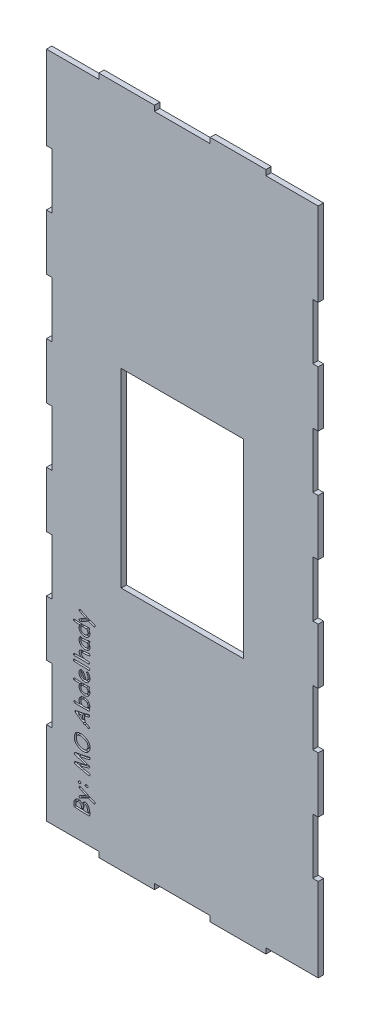
from build123d import *

# Parameters (mm, degrees)
BOSS_EXTRUDE1_DEPTH    = 50
BOSS_EXTRUDE1_2_DEPTH  = 50
BOSS_EXTRUDE1_3_DEPTH  = 50
BOSS_EXTRUDE1_4_DEPTH  = 50
SKETCH1_W              = 1143
SKETCH1_H              = 1778
BOSS_EXTRUDE1_5_DEPTH  = 50
BOSS_EXTRUDE1_6_DEPTH  = 50
BOSS_EXTRUDE1_7_DEPTH  = 50
BOSS_EXTRUDE1_8_DEPTH  = 50
BOSS_EXTRUDE1_9_DEPTH  = 50
BOSS_EXTRUDE1_10_DEPTH = 50
BOSS_EXTRUDE2_DEPTH    = 30
SCALE1_SCALE           = 0.04


with BuildPart() as part:
    # Sketch1 → Boss-Extrude1 (new body)
    with BuildSketch(Plane.XY):
        with BuildLine():
            ThreePointArc((364.602054386, 367.479719192), (356.103541918, 357.918130667), (351.763572316, 345.884288672))
            Line((351.763572316, 345.884288672), (349.060652398, 338.340317984))
            ThreePointArc((349.060652398, 338.340317984), (347.635408414, 324.356297827), (346.919418428, 310.318082182))
            ThreePointArc((346.919418428, 310.318082182), (367.025808597, 309.852333871), (387.137378124, 309.759499352))
            ThreePointArc((387.137378124, 309.759499352), (384.434694065, 333.914018803), (376.327369264, 356.82725942))
            ThreePointArc((376.327369264, 356.82725942), (371.535753699, 363.33240042), (364.602054386, 367.479719192))
        make_face()
    extrude(amount=BOSS_EXTRUDE1_DEPTH)



with BuildPart() as body_2:
    # Sketch1 → Boss-Extrude1 2 (new body)
    with BuildSketch(Plane.XY):
        with BuildLine():
            ThreePointArc((293.795869354, 894.76440173), (283.089924567, 880.6651647), (280.051036544, 863.224668772))
            Line((280.051036544, 863.224668772), (279.79638859, 858.287782786))
            ThreePointArc((279.79638859, 858.287782786), (288.522942613, 833.431164151), (308.39408095, 816.135439354))
            ThreePointArc((308.39408095, 816.135439354), (335.994182242, 805.80189598), (365.324004682, 808.684468734))
            ThreePointArc((365.324004682, 808.684468734), (388.054256437, 850.794430281), (360.561210296, 889.961324722))
            ThreePointArc((360.561210296, 889.961324722), (327.74688214, 900.263125567), (293.795869354, 894.76440173))
        make_face()
    extrude(amount=BOSS_EXTRUDE1_2_DEPTH)


with BuildPart() as body_3:
    # Sketch1 → Boss-Extrude1 3 (new body)
    with BuildSketch(Plane.XY):
        Polygon((334.072014608, 1075.483384462), (298.136522852, 1067.942517146), (341.054299348, 1041.316738292), align=None)
    extrude(amount=BOSS_EXTRUDE1_3_DEPTH)


with BuildPart() as body_4:
    # Sketch1 → Boss-Extrude1 4 (new body)
    with BuildSketch(Plane.XY):
        with BuildLine():
            ThreePointArc((321.224610788, 1402.905986918), (329.409666221, 1384.822326042), (346.998192972, 1375.621366862))
            Line((346.998192972, 1375.621366862), (356.508422618, 1372.742517146))
            ThreePointArc((356.508422618, 1372.742517146), (343.736107756, 1399.648767607), (328.672381262, 1425.342394928))
            ThreePointArc((328.672381262, 1425.342394928), (322.990411802, 1414.774177403), (321.224610788, 1402.905986918))
        make_face()
    extrude(amount=BOSS_EXTRUDE1_4_DEPTH)


with BuildPart() as body_5:
    # Sketch1 → Boss-Extrude1 5 (new body)
    with BuildSketch(Plane.XY):
        Polygon((488.95, 6299.2), (0, 6299.2), (0, 5518.15), (50.8, 5518.15), (50.8, 4997.45), (0, 4997.45), (0, 4476.75), (50.8, 4476.75), (50.8, 3956.05), (0, 3956.05), (0, 3435.35), (50.8, 3435.35), (50.8, 2914.65), (0, 2914.65), (0, 2393.95), (50.8, 2393.95), (50.8, 1873.25), (0, 1873.25), (0, 1352.55), (50.8, 1352.55), (50.8, 831.85), (0, 831.85), (0, 50.8), (488.95, 50.8), (488.95, 0), (1009.65, 0), (1009.65, 50.8), (1530.35, 50.8), (1530.35, 0), (2051.05, 0), (2051.05, 50.8), (2540, 50.8), (2540, 831.85), (2489.2, 831.85), (2489.2, 1352.55), (2540, 1352.55), (2540, 1873.25), (2489.2, 1873.25), (2489.2, 2393.95), (2540, 2393.95), (2540, 2914.65), (2489.2, 2914.65), (2489.2, 3435.35), (2540, 3435.35), (2540, 3956.05), (2489.2, 3956.05), (2489.2, 4476.75), (2540, 4476.75), (2540, 4997.45), (2489.2, 4997.45), (2489.2, 5518.15), (2540, 5518.15), (2540, 6299.2), (2051.05, 6299.2), (2051.05, 6350), (1530.35, 6350), (1530.35, 6299.2), (1009.65, 6299.2), (1009.65, 6350), (488.95, 6350), align=None)
        with BuildLine():
            ThreePointArc((296.833163, 518.616258168), (301.04254699, 527.3167164), (310.404009112, 529.720861562))
            Line((310.404009112, 529.720861562), (312.752772004, 529.934209116))
            ThreePointArc((312.752772004, 529.934209116), (322.160831041, 520.391753474), (312.752772004, 510.849297832))
            ThreePointArc((312.752772004, 510.849297832), (302.910933634, 510.875253047), (296.833163, 518.616258168))
        make_face(mode=Mode.SUBTRACT)
        with BuildLine():
            ThreePointArc((398.029742166, 356.02877232), (405.014628635, 327.732326972), (405.291318194, 298.587843768))
            ThreePointArc((405.291318194, 298.587843768), (396.666611095, 292.034543239), (385.85783382, 291.32626774))
            ThreePointArc((385.85783382, 291.32626774), (324.264844298, 292.744290856), (262.79286278, 296.855572404))
            ThreePointArc((262.79286278, 296.855572404), (258.639720091, 301.567357798), (257.541942878, 307.751563566))
            ThreePointArc((257.541942878, 307.751563566), (257.662270063, 340.716793903), (275.487155146, 368.447541488))
            ThreePointArc((275.487155146, 368.447541488), (307.315367517, 376.072902168), (335.284216908, 359.075117256))
            ThreePointArc((335.284216908, 359.075117256), (335.669623761, 358.33895043), (336.405790484, 358.72435748))
            ThreePointArc((336.405790484, 358.72435748), (345.116517247, 374.13793343), (359.2813871, 384.75921143))
            ThreePointArc((359.2813871, 384.75921143), (374.479955795, 383.614910379), (386.508972472, 374.254959896))
            ThreePointArc((386.508972472, 374.254959896), (392.906026119, 365.544304335), (398.029742166, 356.02877232))
        make_face(mode=Mode.SUBTRACT)
        with BuildLine():
            ThreePointArc((307.973786155, 473.848361169), (307.032158337, 485.749771307), (318.710988477, 488.226695363))
            ThreePointArc((318.710988477, 488.226695363), (380.882556482, 459.304064262), (444.29300905, 433.209295378))
            ThreePointArc((444.29300905, 433.209295378), (450.625721654, 430.763950244), (454.912087888, 425.499918874))
            ThreePointArc((454.912087888, 425.499918874), (451.270170402, 415.332204503), (440.483090838, 414.798450818))
            ThreePointArc((440.483090838, 414.798450818), (416.407170412, 423.672140626), (392.816303012, 433.764875166))
            ThreePointArc((392.816303012, 433.764875166), (354.556055846, 413.360834042), (315.786186816, 393.942578128))
            ThreePointArc((315.786186816, 393.942578128), (305.690485268, 402.245428226), (313.131232279, 412.992325147))
            ThreePointArc((313.131232279, 412.992325147), (341.489667794, 429.428186775), (370.938477599, 443.819365093))
            ThreePointArc((370.938477599, 443.819365093), (338.817842293, 457.495499817), (307.973786155, 473.848361169))
        make_face(mode=Mode.SUBTRACT)
        with BuildLine():
            ThreePointArc((364.444952797, 513.74694586), (363.089015354, 525.419049684), (373.452100186, 530.95827768))
            Line((373.452100186, 530.95827768), (380.713676214, 531.51686051))
            ThreePointArc((380.713676214, 531.51686051), (390.121734194, 521.97440473), (380.713676165, 512.431948998))
            ThreePointArc((380.713676165, 512.431948998), (372.438527222, 511.34767219), (364.444952797, 513.74694586))
        make_face(mode=Mode.SUBTRACT)
        with BuildLine():
            ThreePointArc((400.692320026, 679.918338662), (358.204091549, 666.637343998), (314.66757488, 657.352620268))
            Line((314.66757488, 657.352620268), (309.12198399, 656.173915996))
            ThreePointArc((309.12198399, 656.173915996), (354.753511067, 645.804400773), (400.543364776, 636.158033243))
            ThreePointArc((400.543364776, 636.158033243), (406.842569101, 624.27922809), (395.183630002, 617.581831128))
            ThreePointArc((395.183630002, 617.581831128), (364.296334178, 622.604908956), (334.072014608, 630.713352744))
            Line((334.072014608, 630.713352744), (275.080760226, 643.87604397))
            ThreePointArc((275.080760226, 643.87604397), (266.85028211, 647.552390968), (261.089037638, 654.485237382))
            ThreePointArc((261.089037638, 654.485237382), (263.482440946, 663.654840013), (272.024994938, 667.757858792))
            Line((272.024994938, 667.757858792), (347.99575181, 684.419911574))
            Line((347.99575181, 684.419911574), (367.307689564, 689.502688048))
            ThreePointArc((367.307689564, 689.502688048), (318.662047534, 705.420495656), (269.32296148, 719.037752168))
            ThreePointArc((269.32296148, 719.037752168), (261.048950822, 724.700035587), (260.322464114, 734.699681728))
            ThreePointArc((260.322464114, 734.699681728), (272.547597654, 742.098905096), (286.602823034, 744.678253084))
            ThreePointArc((286.602823034, 744.678253084), (340.00069894, 754.036141162), (392.773335102, 766.443884432))
            ThreePointArc((392.773335102, 766.443884432), (403.340388587, 766.816394214), (409.480689038, 758.20836928))
            ThreePointArc((409.480689038, 758.20836928), (404.752784952, 750.512685523), (396.521568652, 746.794661348))
            ThreePointArc((396.521568652, 746.794661348), (352.251300318, 737.225183726), (307.632429946, 729.441356456))
            ThreePointArc((307.632429946, 729.441356456), (353.696952868, 714.630084404), (399.123633552, 697.964829112))
            ThreePointArc((399.123633552, 697.964829112), (405.127119098, 689.395256471), (400.692320026, 679.918338662))
        make_face(mode=Mode.SUBTRACT)
        with BuildLine():
            ThreePointArc((407.432552164, 849.909041098), (397.118481173, 813.005048304), (367.119045542, 789.165614452))
            ThreePointArc((367.119045542, 789.165614452), (310.779591158, 793.066276398), (267.753159692, 829.645990438))
            ThreePointArc((267.753159692, 829.645990438), (260.713840394, 867.674486477), (274.489852086, 903.812278732))
            ThreePointArc((274.489852086, 903.812278732), (294.401826769, 915.550132715), (317.227505752, 919.190507818))
            ThreePointArc((317.227505752, 919.190507818), (363.899009872, 909.810396122), (400.031330492, 878.81569982))
            ThreePointArc((400.031330492, 878.81569982), (405.468396548, 864.806970097), (407.432552164, 849.909041098))
        make_face(mode=Mode.SUBTRACT)
        with BuildLine():
            ThreePointArc((400.853688517, 1012.366117246), (401.108323828, 999.738593356), (388.531249098, 998.582570014))
            Line((388.531249098, 998.582570014), (359.95301644, 1010.529517672))
            ThreePointArc((359.95301644, 1010.529517672), (350.628089876, 1010.614875598), (345.243670192, 1018.228650356))
            ThreePointArc((345.243670192, 1018.228650356), (305.276069911, 1041.513295189), (267.306411284, 1067.930879882))
            ThreePointArc((267.306411284, 1067.930879882), (264.770421314, 1074.879482878), (269.459282264, 1080.60040166))
            ThreePointArc((269.459282264, 1080.60040166), (296.048691133, 1087.042205001), (322.931391474, 1092.122944782))
            ThreePointArc((322.931391474, 1092.122944782), (351.876214883, 1098.09874472), (380.38225041, 1105.903802412))
            ThreePointArc((380.38225041, 1105.903802412), (389.347948352, 1109.014477886), (398.821067736, 1109.580208064))
            ThreePointArc((398.821067736, 1109.580208064), (402.782653414, 1105.910026555), (404.546541172, 1100.805803464))
            ThreePointArc((404.546541172, 1100.805803464), (399.307868421, 1093.120169441), (391.0570411, 1088.82639359))
            ThreePointArc((391.0570411, 1088.82639359), (372.309327299, 1083.685834533), (353.250023242, 1079.858949498))
            ThreePointArc((353.250023242, 1079.858949498), (357.570547363, 1054.742833849), (363.600321825, 1029.981411962))
            ThreePointArc((363.600321825, 1029.981411962), (382.578519169, 1021.917157213), (400.853688517, 1012.366117246))
        make_face(mode=Mode.SUBTRACT)
        with BuildLine():
            ThreePointArc((257.15051186, 1154.359926988), (266.118841383, 1155.891648274), (275.18384892, 1155.11528311))
            Line((275.18384892, 1155.11528311), (314.987103324, 1154.709041098))
            ThreePointArc((314.987103324, 1154.709041098), (304.650342929, 1180.565261338), (311.362133688, 1207.590149966))
            ThreePointArc((311.362133688, 1207.590149966), (349.921694176, 1228.307837632), (391.266017568, 1213.930452246))
            ThreePointArc((391.266017568, 1213.930452246), (401.758211762, 1198.530984035), (405.663706832, 1180.310751642))
            ThreePointArc((405.663706832, 1180.310751642), (403.894732846, 1167.149256498), (400.07787904, 1154.42974981))
            ThreePointArc((400.07787904, 1154.42974981), (403.189893635, 1143.530661817), (392.901641932, 1138.773915996))
            ThreePointArc((392.901641932, 1138.773915996), (328.927994708, 1138.092684118), (264.959033454, 1139.123999878))
            ThreePointArc((264.959033454, 1139.123999878), (256.742078026, 1144.531676595), (257.15051186, 1154.359926988))
        make_face(mode=Mode.SUBTRACT)
        with BuildLine():
            ThreePointArc((258.017478879, 1323.453405923), (254.736621523, 1335.117443268), (266.156124532, 1339.168213962))
            Line((266.156124532, 1339.168213962), (319.548862552, 1335.68985973))
            ThreePointArc((319.548862552, 1335.68985973), (358.592836344, 1335.324217194), (397.587530706, 1337.319059418))
            ThreePointArc((397.587530706, 1337.319059418), (403.970578604, 1328.649607544), (396.598373951, 1320.804016755))
            ThreePointArc((396.598373951, 1320.804016755), (398.597590637, 1315.613452139), (401.603239713, 1310.933184837))
            ThreePointArc((401.603239713, 1310.933184837), (396.682153097, 1264.425164874), (353.270847427, 1247.027706603))
            ThreePointArc((353.270847427, 1247.027706603), (320.908443546, 1258.957543649), (305.063167363, 1289.593689289))
            ThreePointArc((305.063167363, 1289.593689289), (306.465555063, 1305.526539646), (314.428520489, 1319.397862345))
            ThreePointArc((314.428520489, 1319.397862345), (286.151104792, 1320.425604009), (258.017478879, 1323.453405923))
        make_face(mode=Mode.SUBTRACT)
        with BuildLine():
            ThreePointArc((406.036095216, 1405.419609272), (400.618323077, 1380.025845103), (382.632142024, 1361.299051336))
            ThreePointArc((382.632142024, 1361.299051336), (345.83682468, 1358.368204346), (313.823389116, 1376.742784228))
            ThreePointArc((313.823389116, 1376.742784228), (304.296643932, 1404.984185302), (313.322992098, 1433.389477894))
            ThreePointArc((313.322992098, 1433.389477894), (333.560195461, 1438.935622101), (348.967555302, 1424.690715002))
            ThreePointArc((348.967555302, 1424.690715002), (361.638739389, 1399.672434907), (373.638294378, 1374.325168286))
            ThreePointArc((373.638294378, 1374.325168286), (387.500859734, 1394.384702981), (387.154002678, 1418.76574768))
            ThreePointArc((387.154002678, 1418.76574768), (382.456832319, 1429.57637291), (374.778734312, 1438.519517672))
            ThreePointArc((374.778734312, 1438.519517672), (378.966240567, 1448.970756408), (389.99429621, 1446.702367448))
            ThreePointArc((389.99429621, 1446.702367448), (402.014799366, 1427.615168379), (406.036095216, 1405.419609272))
        make_face(mode=Mode.SUBTRACT)
        with BuildLine():
            ThreePointArc((257.197060402, 1473.205956303), (253.174955865, 1485.98992613), (265.638728818, 1490.915529974))
            Line((265.638728818, 1490.915529974), (328.579283912, 1490.044899508))
            ThreePointArc((328.579283912, 1490.044899508), (364.583778523, 1489.315955792), (400.5200905, 1486.984331334))
            ThreePointArc((400.5200905, 1486.984331334), (404.53874298, 1474.64092392), (392.505979257, 1469.770413522))
            ThreePointArc((392.505979257, 1469.770413522), (324.846617774, 1471.295117352), (257.197060402, 1473.205956303))
        make_face(mode=Mode.SUBTRACT)
        with BuildLine():
            ThreePointArc((265.190881352, 1539.13573173), (293.422410526, 1539.833160152), (321.654289888, 1539.150054282))
            Line((321.654289888, 1539.150054282), (326.065661558, 1539.200183468))
            ThreePointArc((326.065661558, 1539.200183468), (309.29364747, 1559.21718308), (307.62544774, 1585.27860744))
            ThreePointArc((307.62544774, 1585.27860744), (317.710759023, 1595.994472542), (332.084593386, 1599.14663914))
            ThreePointArc((332.084593386, 1599.14663914), (365.692461311, 1601.91245371), (399.174060934, 1605.927550648))
            ThreePointArc((399.174060934, 1605.927550648), (405.128397796, 1602.821406623), (407.525649275, 1596.548014915))
            ThreePointArc((407.525649275, 1596.548014915), (403.070502045, 1589.265800067), (394.872419565, 1586.884532845))
            ThreePointArc((394.872419565, 1586.884532845), (364.660194586, 1583.168118296), (334.234934541, 1582.222694315))
            ThreePointArc((334.234934541, 1582.222694315), (326.781089023, 1578.607548769), (324.791394627, 1570.565769953))
            ThreePointArc((324.791394627, 1570.565769953), (333.669669632, 1554.276845664), (349.020892269, 1543.860858669))
            ThreePointArc((349.020892269, 1543.860858669), (356.552631048, 1540.358217189), (364.826133963, 1539.620154933))
            ThreePointArc((364.826133963, 1539.620154933), (382.05302796, 1539.28842486), (398.991745845, 1536.133150223))
            ThreePointArc((398.991745845, 1536.133150223), (401.903896619, 1523.611425474), (389.532513313, 1520.11527217))
            ThreePointArc((389.532513313, 1520.11527217), (331.216024616, 1522.027294077), (272.869962031, 1521.573793764))
            ThreePointArc((272.869962031, 1521.573793764), (264.158355297, 1520.535669844), (255.695869379, 1522.850000254))
            ThreePointArc((255.695869379, 1522.850000254), (254.365594485, 1534.536372914), (265.190881352, 1539.13573173))
        make_face(mode=Mode.SUBTRACT)
        with BuildLine():
            ThreePointArc((407.898037898, 1701.4684792), (403.027879825, 1694.642324378), (397.005673856, 1688.807269572))
            ThreePointArc((397.005673856, 1688.807269572), (404.004231443, 1673.241777383), (406.374256846, 1656.340672834))
            ThreePointArc((406.374256846, 1656.340672834), (396.50097768, 1632.637741616), (373.267360652, 1621.705695622))
            ThreePointArc((373.267360652, 1621.705695622), (329.255472635, 1629.358187023), (305.148927166, 1666.96777858))
            ThreePointArc((305.148927166, 1666.96777858), (306.705082818, 1686.694838268), (317.774198588, 1703.097678888))
            ThreePointArc((317.774198588, 1703.097678888), (323.411984328, 1703.127323031), (328.848775626, 1701.63507399))
            ThreePointArc((328.848775626, 1701.63507399), (355.066372923, 1699.642276056), (381.112663986, 1703.237324532))
            ThreePointArc((381.112663986, 1703.237324532), (390.627454781, 1707.042542904), (400.465783776, 1709.909285534))
            ThreePointArc((400.465783776, 1709.909285534), (405.722220619, 1707.045147784), (407.898037898, 1701.4684792))
        make_face(mode=Mode.SUBTRACT)
        with BuildLine():
            ThreePointArc((258.017478879, 1799.831414557), (254.736621523, 1811.495451902), (266.156124532, 1815.546222596))
            Line((266.156124532, 1815.546222596), (319.548862552, 1812.067868364))
            ThreePointArc((319.548862552, 1812.067868364), (358.592836344, 1811.702225828), (397.587530706, 1813.697068052))
            ThreePointArc((397.587530706, 1813.697068052), (403.970578511, 1805.027616203), (396.598373999, 1797.182025386))
            ThreePointArc((396.598373999, 1797.182025386), (398.597590662, 1791.991460775), (401.603239713, 1787.311193471))
            ThreePointArc((401.603239713, 1787.311193471), (396.682153097, 1740.803173508), (353.270847427, 1723.405715237))
            ThreePointArc((353.270847427, 1723.405715237), (320.908443595, 1735.335552156), (305.063167363, 1765.971697669))
            ThreePointArc((305.063167363, 1765.971697669), (306.465555063, 1781.904548026), (314.428520489, 1795.775870725))
            ThreePointArc((314.428520489, 1795.775870725), (286.151104787, 1796.803612516), (258.017478879, 1799.831414557))
        make_face(mode=Mode.SUBTRACT)
        with BuildLine():
            ThreePointArc((307.973786155, 1905.496009171), (307.032158284, 1917.397419381), (318.710988461, 1919.87434363))
            ThreePointArc((318.710988461, 1919.87434363), (380.882556473, 1890.951712523), (444.29300905, 1864.856943634))
            ThreePointArc((444.29300905, 1864.856943634), (450.625721688, 1862.411598373), (454.912087888, 1857.147566876))
            ThreePointArc((454.912087888, 1857.147566876), (451.270170317, 1846.979852632), (440.483090838, 1846.446099074))
            ThreePointArc((440.483090838, 1846.446099074), (416.407170415, 1855.319788755), (392.816303012, 1865.412523168))
            ThreePointArc((392.816303012, 1865.412523168), (354.556055844, 1845.008482171), (315.786186816, 1825.590226384))
            ThreePointArc((315.786186816, 1825.590226384), (305.690485268, 1833.893076482), (313.131232279, 1844.639973403))
            ThreePointArc((313.131232279, 1844.639973403), (341.489667798, 1861.075834904), (370.938477599, 1875.467013095))
            ThreePointArc((370.938477599, 1875.467013095), (338.817842293, 1889.143147819), (307.973786155, 1905.496009171))
        make_face(mode=Mode.SUBTRACT)
        with Locations((1270, 3175)):
            Rectangle(SKETCH1_W, SKETCH1_H, mode=Mode.SUBTRACT)
    extrude(amount=BOSS_EXTRUDE1_5_DEPTH)


with BuildPart() as body_6:
    # Sketch1 → Boss-Extrude1 6 (new body)
    with BuildSketch(Plane.XY):
        with BuildLine():
            ThreePointArc((279.649392948, 344.347532792), (275.924642305, 336.489956633), (274.489852086, 327.913439422))
            ThreePointArc((274.489852086, 327.913439422), (274.303894833, 320.713917745), (275.768147218, 313.662417378))
            ThreePointArc((275.768147218, 313.662417378), (301.627756611, 312.961664931), (327.462118506, 311.621442034))
            ThreePointArc((327.462118506, 311.621442034), (326.781637673, 334.446662277), (314.28887485, 353.561698514))
            ThreePointArc((314.28887485, 353.561698514), (294.751415788, 357.291844295), (279.649392948, 344.347532792))
        make_face()
    extrude(amount=BOSS_EXTRUDE1_6_DEPTH)


with BuildPart() as body_7:
    # Sketch1 → Boss-Extrude1 7 (new body)
    with BuildSketch(Plane.XY):
        with BuildLine():
            ThreePointArc((340.999604766, 1208.943937454), (327.222503119, 1199.547397796), (321.596999426, 1183.84844256))
            ThreePointArc((321.596999426, 1183.84844256), (325.971574491, 1168.017082241), (335.715537102, 1154.794976918))
            ThreePointArc((335.715537102, 1154.794976918), (358.484865763, 1154.130052825), (381.229942136, 1155.373416198))
            ThreePointArc((381.229942136, 1155.373416198), (387.63549882, 1175.82042103), (383.227298568, 1196.788943476))
            ThreePointArc((383.227298568, 1196.788943476), (364.127854332, 1209.864681605), (340.999604766, 1208.943937454))
        make_face()
    extrude(amount=BOSS_EXTRUDE1_7_DEPTH)


with BuildPart() as body_8:
    # Sketch1 → Boss-Extrude1 8 (new body)
    with BuildSketch(Plane.XY):
        with BuildLine():
            ThreePointArc((336.0377963, 1317.181434466), (325.830674158, 1307.723597407), (321.96938781, 1294.354734628))
            ThreePointArc((321.96938781, 1294.354734628), (329.212691399, 1273.78534243), (348.65156203, 1263.9012314))
            ThreePointArc((348.65156203, 1263.9012314), (375.42586568, 1268.318739422), (388.38061262, 1292.163073022))
            ThreePointArc((388.38061262, 1292.163073022), (384.470019327, 1306.693613406), (374.3222003, 1317.804469034))
            ThreePointArc((374.3222003, 1317.804469034), (355.171668452, 1318.004806575), (336.0377963, 1317.181434466))
        make_face()
    extrude(amount=BOSS_EXTRUDE1_8_DEPTH)


with BuildPart() as body_9:
    # Sketch1 → Boss-Extrude1 9 (new body)
    with BuildSketch(Plane.XY):
        with BuildLine():
            ThreePointArc((378.305785424, 1684.891870494), (360.776976392, 1683.166605795), (343.195533318, 1682.104276374))
            ThreePointArc((343.195533318, 1682.104276374), (333.75338958, 1683.267644094), (324.246035784, 1683.610757232))
            ThreePointArc((324.246035784, 1683.610757232), (322.144014321, 1666.211331272), (331.137515524, 1651.168876218))
            ThreePointArc((331.137515524, 1651.168876218), (355.844857786, 1639.06039085), (382.854910184, 1644.306841936))
            ThreePointArc((382.854910184, 1644.306841936), (390.711204253, 1662.333024575), (383.50659011, 1680.629421818))
            ThreePointArc((383.50659011, 1680.629421818), (381.563061989, 1683.562127838), (378.305785424, 1684.891870494))
        make_face()
    extrude(amount=BOSS_EXTRUDE1_9_DEPTH)


with BuildPart() as body_10:
    # Sketch1 → Boss-Extrude1 10 (new body)
    with BuildSketch(Plane.XY):
        with BuildLine():
            ThreePointArc((336.0377963, 1793.559442846), (325.830674158, 1784.101605787), (321.96938781, 1770.732743008))
            ThreePointArc((321.96938781, 1770.732743008), (329.212691449, 1750.163350937), (348.65156203, 1740.279240034))
            ThreePointArc((348.65156203, 1740.279240034), (375.425865618, 1744.696747929), (388.38061262, 1768.541081402))
            ThreePointArc((388.38061262, 1768.541081402), (384.470019357, 1783.071621913), (374.3222003, 1794.182477668))
            ThreePointArc((374.3222003, 1794.182477668), (355.171668449, 1794.382815082), (336.0377963, 1793.559442846))
        make_face()
    extrude(amount=BOSS_EXTRUDE1_10_DEPTH)


with BuildPart() as part_1:
    add(part.part)

    add(body_2.part)  # Boss-Extrude2 merges body 2

    add(body_3.part)  # Boss-Extrude2 merges body 3

    add(body_4.part)  # Boss-Extrude2 merges body 4

    add(body_5.part)  # Boss-Extrude2 merges body 5

    add(body_6.part)  # Boss-Extrude2 merges body 6

    add(body_7.part)  # Boss-Extrude2 merges body 7

    add(body_8.part)  # Boss-Extrude2 merges body 8

    add(body_9.part)  # Boss-Extrude2 merges body 9

    add(body_10.part)  # Boss-Extrude2 merges body 10
    # Sketch1_3 → Boss-Extrude2 (add)
    # profile 1 of 15: a face of its own
    with BuildSketch(Plane.XY):
        with BuildLine():
            Line((380.713676214, 531.51686051), (373.452100186, 530.95827768))
            ThreePointArc((373.452100186, 530.95827768), (363.089015354, 525.419049684), (364.444952797, 513.74694586))
            ThreePointArc((364.444952797, 513.74694586), (372.438527222, 511.34767219), (380.713676165, 512.431948998))
            ThreePointArc((380.713676165, 512.431948998), (390.121734194, 521.97440473), (380.713676214, 531.51686051))
        make_face()
    # profile 2 of 15: a face of its own
    with BuildSketch(Plane.XY):
        with BuildLine():
            Line((312.752772004, 529.934209116), (310.404009112, 529.720861562))
            ThreePointArc((310.404009112, 529.720861562), (301.04254699, 527.3167164), (296.833163, 518.616258168))
            ThreePointArc((296.833163, 518.616258168), (302.910933634, 510.875253047), (312.752772004, 510.849297832))
            ThreePointArc((312.752772004, 510.849297832), (322.160831041, 520.391753474), (312.752772004, 529.934209116))
        make_face()
    # profile 3 of 15: a face of its own
    with BuildSketch(Plane.XY):
        with BuildLine():
            Line((309.12198399, 656.173915996), (314.66757488, 657.352620268))
            ThreePointArc((314.66757488, 657.352620268), (358.204091549, 666.637343998), (400.692320026, 679.918338662))
            ThreePointArc((400.692320026, 679.918338662), (405.127119098, 689.395256471), (399.123633552, 697.964829112))
            ThreePointArc((399.123633552, 697.964829112), (353.696952868, 714.630084404), (307.632429946, 729.441356456))
            ThreePointArc((307.632429946, 729.441356456), (352.251300318, 737.225183726), (396.521568652, 746.794661348))
            ThreePointArc((396.521568652, 746.794661348), (404.752784952, 750.512685523), (409.480689038, 758.20836928))
            ThreePointArc((409.480689038, 758.20836928), (403.340388587, 766.816394214), (392.773335102, 766.443884432))
            ThreePointArc((392.773335102, 766.443884432), (340.00069894, 754.036141162), (286.602823034, 744.678253084))
            ThreePointArc((286.602823034, 744.678253084), (272.547597654, 742.098905096), (260.322464114, 734.699681728))
            ThreePointArc((260.322464114, 734.699681728), (261.048950822, 724.700035587), (269.32296148, 719.037752168))
            ThreePointArc((269.32296148, 719.037752168), (318.662047534, 705.420495656), (367.307689564, 689.502688048))
            Line((367.307689564, 689.502688048), (347.99575181, 684.419911574))
            Line((347.99575181, 684.419911574), (272.024994938, 667.757858792))
            ThreePointArc((272.024994938, 667.757858792), (263.482440946, 663.654840013), (261.089037638, 654.485237382))
            ThreePointArc((261.089037638, 654.485237382), (266.85028211, 647.552390968), (275.080760226, 643.87604397))
            Line((275.080760226, 643.87604397), (334.072014608, 630.713352744))
            ThreePointArc((334.072014608, 630.713352744), (364.296334178, 622.604908956), (395.183630002, 617.581831128))
            ThreePointArc((395.183630002, 617.581831128), (406.842569101, 624.27922809), (400.543364776, 636.158033243))
            ThreePointArc((400.543364776, 636.158033243), (354.753511067, 645.804400773), (309.12198399, 656.173915996))
        make_face()
    # profile 4 of 15: a face of its own
    with BuildSketch(Plane.XY):
        with BuildLine():
            Line((359.95301644, 1010.529517672), (388.531249098, 998.582570014))
            ThreePointArc((388.531249098, 998.582570014), (401.108323828, 999.738593356), (400.853688517, 1012.366117246))
            ThreePointArc((400.853688517, 1012.366117246), (382.578519169, 1021.917157213), (363.600321825, 1029.981411962))
            ThreePointArc((363.600321825, 1029.981411962), (357.570547363, 1054.742833849), (353.250023242, 1079.858949498))
            ThreePointArc((353.250023242, 1079.858949498), (372.309327299, 1083.685834533), (391.0570411, 1088.82639359))
            ThreePointArc((391.0570411, 1088.82639359), (399.307868421, 1093.120169441), (404.546541172, 1100.805803464))
            ThreePointArc((404.546541172, 1100.805803464), (402.782653414, 1105.910026555), (398.821067736, 1109.580208064))
            ThreePointArc((398.821067736, 1109.580208064), (389.347948352, 1109.014477886), (380.38225041, 1105.903802412))
            ThreePointArc((380.38225041, 1105.903802412), (351.876214883, 1098.09874472), (322.931391474, 1092.122944782))
            ThreePointArc((322.931391474, 1092.122944782), (296.048691133, 1087.042205001), (269.459282264, 1080.60040166))
            ThreePointArc((269.459282264, 1080.60040166), (264.770421314, 1074.879482878), (267.306411284, 1067.930879882))
            ThreePointArc((267.306411284, 1067.930879882), (305.276069911, 1041.513295189), (345.243670192, 1018.228650356))
            ThreePointArc((345.243670192, 1018.228650356), (350.628089876, 1010.614875598), (359.95301644, 1010.529517672))
        make_face()
        Polygon((341.054299348, 1041.316738292), (298.136522852, 1067.942517146), (334.072014608, 1075.483384462), align=None, mode=Mode.SUBTRACT)
    # profile 5 of 15: a face of its own
    with BuildSketch(Plane.XY):
        with BuildLine():
            Line((314.987103324, 1154.709041098), (275.18384892, 1155.11528311))
            ThreePointArc((275.18384892, 1155.11528311), (266.118841383, 1155.891648274), (257.15051186, 1154.359926988))
            ThreePointArc((257.15051186, 1154.359926988), (256.742078026, 1144.531676595), (264.959033454, 1139.123999878))
            ThreePointArc((264.959033454, 1139.123999878), (328.927994708, 1138.092684118), (392.901641932, 1138.773915996))
            ThreePointArc((392.901641932, 1138.773915996), (403.189893635, 1143.530661817), (400.07787904, 1154.42974981))
            ThreePointArc((400.07787904, 1154.42974981), (403.894732846, 1167.149256498), (405.663706832, 1180.310751642))
            ThreePointArc((405.663706832, 1180.310751642), (401.758211762, 1198.530984035), (391.266017568, 1213.930452246))
            ThreePointArc((391.266017568, 1213.930452246), (349.921694176, 1228.307837632), (311.362133688, 1207.590149966))
            ThreePointArc((311.362133688, 1207.590149966), (304.650342929, 1180.565261338), (314.987103324, 1154.709041098))
        make_face()
        with BuildLine():
            ThreePointArc((335.715537102, 1154.794976918), (325.971574491, 1168.017082241), (321.596999426, 1183.84844256))
            ThreePointArc((321.596999426, 1183.84844256), (327.222503119, 1199.547397796), (340.999604766, 1208.943937454))
            ThreePointArc((340.999604766, 1208.943937454), (364.127854332, 1209.864681605), (383.227298568, 1196.788943476))
            ThreePointArc((383.227298568, 1196.788943476), (387.63549882, 1175.82042103), (381.229942136, 1155.373416198))
            ThreePointArc((381.229942136, 1155.373416198), (358.484865763, 1154.130052825), (335.715537102, 1154.794976918))
        make_face(mode=Mode.SUBTRACT)
    # profile 6 of 15: a face of its own
    with BuildSketch(Plane.XY):
        with BuildLine():
            Line((319.548862552, 1335.68985973), (266.156124532, 1339.168213962))
            ThreePointArc((266.156124532, 1339.168213962), (254.736621523, 1335.117443268), (258.017478879, 1323.453405923))
            ThreePointArc((258.017478879, 1323.453405923), (286.151104792, 1320.425604009), (314.428520489, 1319.397862345))
            ThreePointArc((314.428520489, 1319.397862345), (306.465555063, 1305.526539646), (305.063167363, 1289.593689289))
            ThreePointArc((305.063167363, 1289.593689289), (320.908443546, 1258.957543649), (353.270847427, 1247.027706603))
            ThreePointArc((353.270847427, 1247.027706603), (396.682153097, 1264.425164874), (401.603239713, 1310.933184837))
            ThreePointArc((401.603239713, 1310.933184837), (398.597590637, 1315.613452139), (396.598373951, 1320.804016755))
            ThreePointArc((396.598373951, 1320.804016755), (403.970578604, 1328.649607544), (397.587530706, 1337.319059418))
            ThreePointArc((397.587530706, 1337.319059418), (358.592836344, 1335.324217194), (319.548862552, 1335.68985973))
        make_face()
        with BuildLine():
            ThreePointArc((348.65156203, 1263.9012314), (329.212691399, 1273.78534243), (321.96938781, 1294.354734628))
            ThreePointArc((321.96938781, 1294.354734628), (325.830674158, 1307.723597407), (336.0377963, 1317.181434466))
            ThreePointArc((336.0377963, 1317.181434466), (355.171668452, 1318.004806575), (374.3222003, 1317.804469034))
            ThreePointArc((374.3222003, 1317.804469034), (384.470019327, 1306.693613406), (388.38061262, 1292.163073022))
            ThreePointArc((388.38061262, 1292.163073022), (375.42586568, 1268.318739422), (348.65156203, 1263.9012314))
        make_face(mode=Mode.SUBTRACT)
    # profile 7 of 15: a face of its own
    with BuildSketch(Plane.XY):
        with BuildLine():
            Line((328.579283912, 1490.044899508), (265.638728818, 1490.915529974))
            ThreePointArc((265.638728818, 1490.915529974), (253.174955865, 1485.98992613), (257.197060402, 1473.205956303))
            ThreePointArc((257.197060402, 1473.205956303), (324.846617774, 1471.295117352), (392.505979257, 1469.770413522))
            ThreePointArc((392.505979257, 1469.770413522), (404.53874298, 1474.64092392), (400.5200905, 1486.984331334))
            ThreePointArc((400.5200905, 1486.984331334), (364.583778523, 1489.315955792), (328.579283912, 1490.044899508))
        make_face()
    # profile 8 of 15: a face of its own
    with BuildSketch(Plane.XY):
        with BuildLine():
            Line((326.065661558, 1539.200183468), (321.654289888, 1539.150054282))
            ThreePointArc((321.654289888, 1539.150054282), (293.422410526, 1539.833160152), (265.190881352, 1539.13573173))
            ThreePointArc((265.190881352, 1539.13573173), (254.365594485, 1534.536372914), (255.695869379, 1522.850000254))
            ThreePointArc((255.695869379, 1522.850000254), (264.158355297, 1520.535669844), (272.869962031, 1521.573793764))
            ThreePointArc((272.869962031, 1521.573793764), (331.216024616, 1522.027294077), (389.532513313, 1520.11527217))
            ThreePointArc((389.532513313, 1520.11527217), (401.903896619, 1523.611425474), (398.991745845, 1536.133150223))
            ThreePointArc((398.991745845, 1536.133150223), (382.05302796, 1539.28842486), (364.826133963, 1539.620154933))
            ThreePointArc((364.826133963, 1539.620154933), (356.552631048, 1540.358217189), (349.020892269, 1543.860858669))
            ThreePointArc((349.020892269, 1543.860858669), (333.669669632, 1554.276845664), (324.791394627, 1570.565769953))
            ThreePointArc((324.791394627, 1570.565769953), (326.781089023, 1578.607548769), (334.234934541, 1582.222694315))
            ThreePointArc((334.234934541, 1582.222694315), (364.660194586, 1583.168118296), (394.872419565, 1586.884532845))
            ThreePointArc((394.872419565, 1586.884532845), (403.070502045, 1589.265800067), (407.525649275, 1596.548014915))
            ThreePointArc((407.525649275, 1596.548014915), (405.128397796, 1602.821406623), (399.174060934, 1605.927550648))
            ThreePointArc((399.174060934, 1605.927550648), (365.692461311, 1601.91245371), (332.084593386, 1599.14663914))
            ThreePointArc((332.084593386, 1599.14663914), (317.710759023, 1595.994472542), (307.62544774, 1585.27860744))
            ThreePointArc((307.62544774, 1585.27860744), (309.29364747, 1559.21718308), (326.065661558, 1539.200183468))
        make_face()
    # profile 9 of 15: a face of its own
    with BuildSketch(Plane.XY):
        with BuildLine():
            Line((319.548862552, 1812.067868364), (266.156124532, 1815.546222596))
            ThreePointArc((266.156124532, 1815.546222596), (254.736621523, 1811.495451902), (258.017478879, 1799.831414557))
            ThreePointArc((258.017478879, 1799.831414557), (286.151104787, 1796.803612516), (314.428520489, 1795.775870725))
            ThreePointArc((314.428520489, 1795.775870725), (306.465555063, 1781.904548026), (305.063167363, 1765.971697669))
            ThreePointArc((305.063167363, 1765.971697669), (320.908443595, 1735.335552156), (353.270847427, 1723.405715237))
            ThreePointArc((353.270847427, 1723.405715237), (396.682153097, 1740.803173508), (401.603239713, 1787.311193471))
            ThreePointArc((401.603239713, 1787.311193471), (398.597590662, 1791.991460775), (396.598373999, 1797.182025386))
            ThreePointArc((396.598373999, 1797.182025386), (403.970578511, 1805.027616203), (397.587530706, 1813.697068052))
            ThreePointArc((397.587530706, 1813.697068052), (358.592836344, 1811.702225828), (319.548862552, 1812.067868364))
        make_face()
        with BuildLine():
            ThreePointArc((348.65156203, 1740.279240034), (329.212691449, 1750.163350937), (321.96938781, 1770.732743008))
            ThreePointArc((321.96938781, 1770.732743008), (325.830674158, 1784.101605787), (336.0377963, 1793.559442846))
            ThreePointArc((336.0377963, 1793.559442846), (355.171668449, 1794.382815082), (374.3222003, 1794.182477668))
            ThreePointArc((374.3222003, 1794.182477668), (384.470019357, 1783.071621913), (388.38061262, 1768.541081402))
            ThreePointArc((388.38061262, 1768.541081402), (375.425865618, 1744.696747929), (348.65156203, 1740.279240034))
        make_face(mode=Mode.SUBTRACT)
    # profile 10 of 15: a face of its own
    with BuildSketch(Plane.XY):
        with BuildLine():
            ThreePointArc((385.85783382, 291.32626774), (396.666611095, 292.034543239), (405.291318194, 298.587843768))
            ThreePointArc((405.291318194, 298.587843768), (405.014628635, 327.732326972), (398.029742166, 356.02877232))
            ThreePointArc((398.029742166, 356.02877232), (392.906026119, 365.544304335), (386.508972472, 374.254959896))
            ThreePointArc((386.508972472, 374.254959896), (374.479955795, 383.614910379), (359.2813871, 384.75921143))
            ThreePointArc((359.2813871, 384.75921143), (345.116517247, 374.13793343), (336.405790484, 358.72435748))
            ThreePointArc((336.405790484, 358.72435748), (335.669623761, 358.33895043), (335.284216908, 359.075117256))
            ThreePointArc((335.284216908, 359.075117256), (307.315367517, 376.072902168), (275.487155146, 368.447541488))
            ThreePointArc((275.487155146, 368.447541488), (257.662270063, 340.716793903), (257.541942878, 307.751563566))
            ThreePointArc((257.541942878, 307.751563566), (258.639720091, 301.567357798), (262.79286278, 296.855572404))
            ThreePointArc((262.79286278, 296.855572404), (324.264844298, 292.744290856), (385.85783382, 291.32626774))
        make_face()
        with BuildLine():
            ThreePointArc((275.768147218, 313.662417378), (274.303894833, 320.713917745), (274.489852086, 327.913439422))
            ThreePointArc((274.489852086, 327.913439422), (275.924642305, 336.489956633), (279.649392948, 344.347532792))
            ThreePointArc((279.649392948, 344.347532792), (294.751415788, 357.291844295), (314.28887485, 353.561698514))
            ThreePointArc((314.28887485, 353.561698514), (326.781637673, 334.446662277), (327.462118506, 311.621442034))
            ThreePointArc((327.462118506, 311.621442034), (301.627756611, 312.961664931), (275.768147218, 313.662417378))
        make_face(mode=Mode.SUBTRACT)
        with BuildLine():
            Line((349.060652398, 338.340317984), (351.763572316, 345.884288672))
            ThreePointArc((351.763572316, 345.884288672), (356.103541918, 357.918130667), (364.602054386, 367.479719192))
            ThreePointArc((364.602054386, 367.479719192), (371.535753699, 363.33240042), (376.327369264, 356.82725942))
            ThreePointArc((376.327369264, 356.82725942), (384.434694065, 333.914018803), (387.137378124, 309.759499352))
            ThreePointArc((387.137378124, 309.759499352), (367.025808597, 309.852333871), (346.919418428, 310.318082182))
            ThreePointArc((346.919418428, 310.318082182), (347.635408414, 324.356297827), (349.060652398, 338.340317984))
        make_face(mode=Mode.SUBTRACT)
    # profile 11 of 15: a face of its own
    with BuildSketch(Plane.XY):
        with BuildLine():
            ThreePointArc((444.29300905, 433.209295378), (380.882556482, 459.304064262), (318.710988477, 488.226695363))
            ThreePointArc((318.710988477, 488.226695363), (307.032158337, 485.749771307), (307.973786155, 473.848361169))
            ThreePointArc((307.973786155, 473.848361169), (338.817842293, 457.495499817), (370.938477599, 443.819365093))
            ThreePointArc((370.938477599, 443.819365093), (341.489667794, 429.428186775), (313.131232279, 412.992325147))
            ThreePointArc((313.131232279, 412.992325147), (305.690485268, 402.245428226), (315.786186816, 393.942578128))
            ThreePointArc((315.786186816, 393.942578128), (354.556055846, 413.360834042), (392.816303012, 433.764875166))
            ThreePointArc((392.816303012, 433.764875166), (416.407170412, 423.672140626), (440.483090838, 414.798450818))
            ThreePointArc((440.483090838, 414.798450818), (451.270170402, 415.332204503), (454.912087888, 425.499918874))
            ThreePointArc((454.912087888, 425.499918874), (450.625721654, 430.763950244), (444.29300905, 433.209295378))
        make_face()
    # profile 12 of 15: a face of its own
    with BuildSketch(Plane.XY):
        with BuildLine():
            ThreePointArc((267.753159692, 829.645990438), (310.779591158, 793.066276398), (367.119045542, 789.165614452))
            ThreePointArc((367.119045542, 789.165614452), (397.118481173, 813.005048304), (407.432552164, 849.909041098))
            ThreePointArc((407.432552164, 849.909041098), (405.468396548, 864.806970097), (400.031330492, 878.81569982))
            ThreePointArc((400.031330492, 878.81569982), (363.899009872, 909.810396122), (317.227505752, 919.190507818))
            ThreePointArc((317.227505752, 919.190507818), (294.401826769, 915.550132715), (274.489852086, 903.812278732))
            ThreePointArc((274.489852086, 903.812278732), (260.713840394, 867.674486477), (267.753159692, 829.645990438))
        make_face()
        with BuildLine():
            Line((279.79638859, 858.287782786), (280.051036544, 863.224668772))
            ThreePointArc((280.051036544, 863.224668772), (283.089924567, 880.6651647), (293.795869354, 894.76440173))
            ThreePointArc((293.795869354, 894.76440173), (327.74688214, 900.263125567), (360.561210296, 889.961324722))
            ThreePointArc((360.561210296, 889.961324722), (388.054256437, 850.794430281), (365.324004682, 808.684468734))
            ThreePointArc((365.324004682, 808.684468734), (335.994182242, 805.80189598), (308.39408095, 816.135439354))
            ThreePointArc((308.39408095, 816.135439354), (288.522942613, 833.431164151), (279.79638859, 858.287782786))
        make_face(mode=Mode.SUBTRACT)
    # profile 13 of 15: a face of its own
    with BuildSketch(Plane.XY):
        with BuildLine():
            ThreePointArc((313.823389116, 1376.742784228), (345.83682468, 1358.368204346), (382.632142024, 1361.299051336))
            ThreePointArc((382.632142024, 1361.299051336), (400.618323077, 1380.025845103), (406.036095216, 1405.419609272))
            ThreePointArc((406.036095216, 1405.419609272), (402.014799366, 1427.615168379), (389.99429621, 1446.702367448))
            ThreePointArc((389.99429621, 1446.702367448), (378.966240567, 1448.970756408), (374.778734312, 1438.519517672))
            ThreePointArc((374.778734312, 1438.519517672), (382.456832319, 1429.57637291), (387.154002678, 1418.76574768))
            ThreePointArc((387.154002678, 1418.76574768), (387.500859734, 1394.384702981), (373.638294378, 1374.325168286))
            ThreePointArc((373.638294378, 1374.325168286), (361.638739389, 1399.672434907), (348.967555302, 1424.690715002))
            ThreePointArc((348.967555302, 1424.690715002), (333.560195461, 1438.935622101), (313.322992098, 1433.389477894))
            ThreePointArc((313.322992098, 1433.389477894), (304.296643932, 1404.984185302), (313.823389116, 1376.742784228))
        make_face()
        with BuildLine():
            Line((356.508422618, 1372.742517146), (346.998192972, 1375.621366862))
            ThreePointArc((346.998192972, 1375.621366862), (329.409666221, 1384.822326042), (321.224610788, 1402.905986918))
            ThreePointArc((321.224610788, 1402.905986918), (322.990411802, 1414.774177403), (328.672381262, 1425.342394928))
            ThreePointArc((328.672381262, 1425.342394928), (343.736107756, 1399.648767607), (356.508422618, 1372.742517146))
        make_face(mode=Mode.SUBTRACT)
    # profile 14 of 15: a face of its own
    with BuildSketch(Plane.XY):
        with BuildLine():
            ThreePointArc((406.374256846, 1656.340672834), (404.004231443, 1673.241777383), (397.005673856, 1688.807269572))
            ThreePointArc((397.005673856, 1688.807269572), (403.027879825, 1694.642324378), (407.898037898, 1701.4684792))
            ThreePointArc((407.898037898, 1701.4684792), (405.722220619, 1707.045147784), (400.465783776, 1709.909285534))
            ThreePointArc((400.465783776, 1709.909285534), (390.627454781, 1707.042542904), (381.112663986, 1703.237324532))
            ThreePointArc((381.112663986, 1703.237324532), (355.066372923, 1699.642276056), (328.848775626, 1701.63507399))
            ThreePointArc((328.848775626, 1701.63507399), (323.411984328, 1703.127323031), (317.774198588, 1703.097678888))
            ThreePointArc((317.774198588, 1703.097678888), (306.705082818, 1686.694838268), (305.148927166, 1666.96777858))
            ThreePointArc((305.148927166, 1666.96777858), (329.255472635, 1629.358187023), (373.267360652, 1621.705695622))
            ThreePointArc((373.267360652, 1621.705695622), (396.50097768, 1632.637741616), (406.374256846, 1656.340672834))
        make_face()
        with BuildLine():
            ThreePointArc((324.246035784, 1683.610757232), (333.75338958, 1683.267644094), (343.195533318, 1682.104276374))
            ThreePointArc((343.195533318, 1682.104276374), (360.776976392, 1683.166605795), (378.305785424, 1684.891870494))
            ThreePointArc((378.305785424, 1684.891870494), (381.563061989, 1683.562127838), (383.50659011, 1680.629421818))
            ThreePointArc((383.50659011, 1680.629421818), (390.711204253, 1662.333024575), (382.854910184, 1644.306841936))
            ThreePointArc((382.854910184, 1644.306841936), (355.844857786, 1639.06039085), (331.137515524, 1651.168876218))
            ThreePointArc((331.137515524, 1651.168876218), (322.144014321, 1666.211331272), (324.246035784, 1683.610757232))
        make_face(mode=Mode.SUBTRACT)
    # profile 15 of 15: a face of its own
    with BuildSketch(Plane.XY):
        with BuildLine():
            ThreePointArc((444.29300905, 1864.856943634), (380.882556473, 1890.951712523), (318.710988461, 1919.87434363))
            ThreePointArc((318.710988461, 1919.87434363), (307.032158284, 1917.397419381), (307.973786155, 1905.496009171))
            ThreePointArc((307.973786155, 1905.496009171), (338.817842293, 1889.143147819), (370.938477599, 1875.467013095))
            ThreePointArc((370.938477599, 1875.467013095), (341.489667798, 1861.075834904), (313.131232279, 1844.639973403))
            ThreePointArc((313.131232279, 1844.639973403), (305.690485268, 1833.893076482), (315.786186816, 1825.590226384))
            ThreePointArc((315.786186816, 1825.590226384), (354.556055844, 1845.008482171), (392.816303012, 1865.412523168))
            ThreePointArc((392.816303012, 1865.412523168), (416.407170415, 1855.319788755), (440.483090838, 1846.446099074))
            ThreePointArc((440.483090838, 1846.446099074), (451.270170317, 1846.979852632), (454.912087888, 1857.147566876))
            ThreePointArc((454.912087888, 1857.147566876), (450.625721688, 1862.411598373), (444.29300905, 1864.856943634))
        make_face()
    extrude(amount=BOSS_EXTRUDE2_DEPTH)


with BuildPart() as part_2:
    # Scale1: scaled about (1272.042966215, 3179.556219378, 24.966901775)
    add(part_1.part.scale(SCALE1_SCALE).moved(Location((1221.161247566, 3052.373970603, 23.968225704))))


solid = part_2.part
